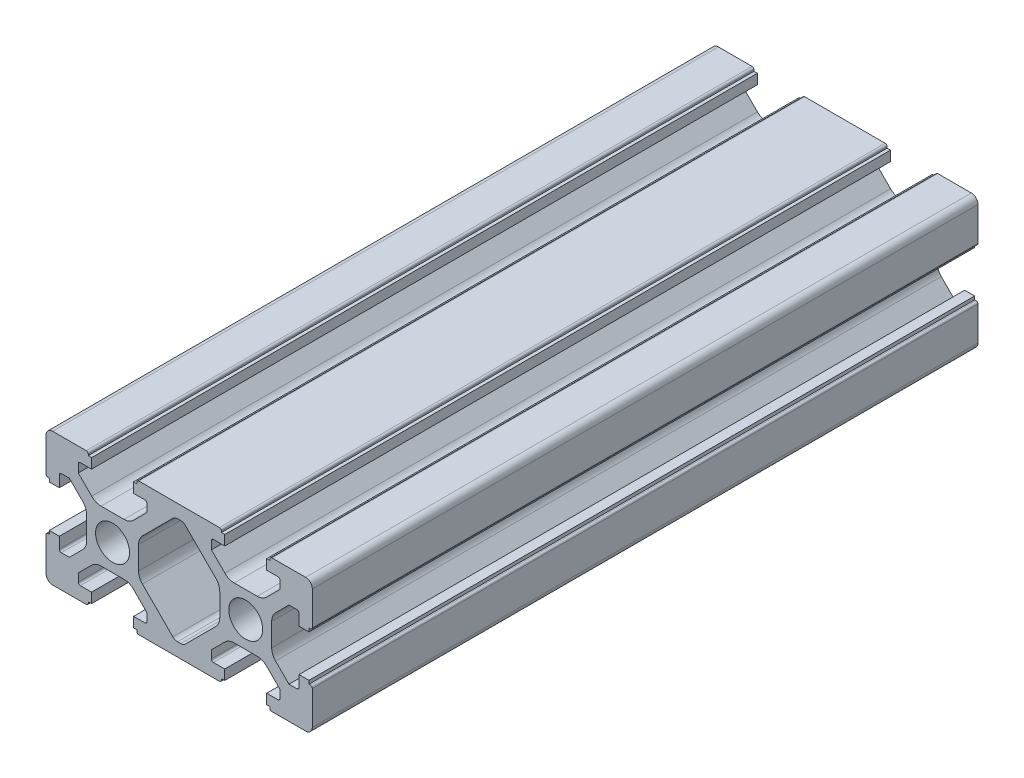
from build123d import *

# Parameters (mm, degrees)
SKETCH_1_R      = 2.55
EXTRUDE_1_DEPTH = 100


with BuildPart() as part:
    # 草图1 → 凸台-拉伸1 (new body)
    with BuildSketch(Plane.XY):
        with BuildLine():
            Line((-23.165408345, -6.388804564), (-23.165408345, -1.338804564))
            ThreePointArc((-23.165408345, -1.338804564), (-23.077540379, -1.12667253), (-22.865408345, -1.038804564))
            Line((-22.865408345, -1.038804564), (-22.665408345, -1.038804564))
            Line((-22.665408345, -1.038804564), (-22.665408345, -0.538804564))
            Line((-22.665408345, -0.538804564), (-21.165408345, -0.538804564))
            Line((-21.165408345, -0.538804564), (-21.165408345, -2.238804564))
            ThreePointArc((-21.165408345, -2.238804564), (-21.077540379, -2.450936598), (-20.865408345, -2.538804564))
            Line((-20.865408345, -2.538804564), (-19.665408345, -2.538804564))
            Line((-19.665408345, -2.538804564), (-17.651194783, -0.524591002))
            ThreePointArc((-17.651194783, -0.524591002), (-17.21764928, 0.124255696), (-17.065408345, 0.889622561))
            Line((-17.065408345, 0.889622561), (-17.065408345, 4.332768311))
            ThreePointArc((-17.065408345, 4.332768311), (-17.21764928, 5.098135176), (-17.651194783, 5.746981874))
            Line((-17.651194783, 5.746981874), (-19.665408345, 7.761195436))
            Line((-19.665408345, 7.761195436), (-20.865408345, 7.761195436))
            ThreePointArc((-20.865408345, 7.761195436), (-21.077540379, 7.67332747), (-21.165408345, 7.461195436))
            Line((-21.165408345, 7.461195436), (-21.165408345, 5.761195436))
            Line((-21.165408345, 5.761195436), (-22.665408345, 5.761195436))
            Line((-22.665408345, 5.761195436), (-22.665408345, 6.261195436))
            Line((-22.665408345, 6.261195436), (-22.865408345, 6.261195436))
            ThreePointArc((-22.865408345, 6.261195436), (-23.077540379, 6.349063402), (-23.165408345, 6.561195436))
            Line((-23.165408345, 6.561195436), (-23.165408345, 11.611195436))
            ThreePointArc((-23.165408345, 11.611195436), (-22.872515126, 12.318302217), (-22.165408345, 12.611195436))
            Line((-22.165408345, 12.611195436), (-17.115408345, 12.611195436))
            ThreePointArc((-17.115408345, 12.611195436), (-16.903276311, 12.52332747), (-16.815408345, 12.311195436))
            Line((-16.815408345, 12.311195436), (-16.815408345, 12.111195436))
            Line((-16.815408345, 12.111195436), (-16.315408345, 12.111195436))
            Line((-16.315408345, 12.111195436), (-16.315408345, 10.611195436))
            Line((-16.315408345, 10.611195436), (-18.015408345, 10.611195436))
            ThreePointArc((-18.015408345, 10.611195436), (-18.227540379, 10.52332747), (-18.315408345, 10.311195436))
            Line((-18.315408345, 10.311195436), (-18.315408345, 9.111195436))
            Line((-18.315408345, 9.111195436), (-16.301194783, 7.096981874))
            ThreePointArc((-16.301194783, 7.096981874), (-15.652348085, 6.663436371), (-14.88698122, 6.511195436))
            Line((-14.88698122, 6.511195436), (-11.44383547, 6.511195436))
            ThreePointArc((-11.44383547, 6.511195436), (-10.678468605, 6.663436371), (-10.029621907, 7.096981874))
            Line((-10.029621907, 7.096981874), (-8.015408345, 9.111195436))
            Line((-8.015408345, 9.111195436), (-8.015408345, 10.311195436))
            ThreePointArc((-8.015408345, 10.311195436), (-8.103276311, 10.52332747), (-8.315408345, 10.611195436))
            Line((-8.315408345, 10.611195436), (-10.015408345, 10.611195436))
            Line((-10.015408345, 10.611195436), (-10.015408345, 12.111195436))
            Line((-10.015408345, 12.111195436), (-9.515408345, 12.111195436))
            Line((-9.515408345, 12.111195436), (-9.515408345, 12.311195436))
            ThreePointArc((-9.515408345, 12.311195436), (-9.427540379, 12.52332747), (-9.215408345, 12.611195436))
            Line((-9.215408345, 12.611195436), (2.884591655, 12.611195436))
            ThreePointArc((2.884591655, 12.611195436), (3.096723689, 12.52332747), (3.184591655, 12.311195436))
            Line((3.184591655, 12.311195436), (3.184591655, 12.111195436))
            Line((3.184591655, 12.111195436), (3.684591655, 12.111195436))
            Line((3.684591655, 12.111195436), (3.684591655, 10.611195436))
            Line((3.684591655, 10.611195436), (1.984591655, 10.611195436))
            ThreePointArc((1.984591655, 10.611195436), (1.772459621, 10.52332747), (1.684591655, 10.311195436))
            Line((1.684591655, 10.311195436), (1.684591655, 9.111195436))
            Line((1.684591655, 9.111195436), (3.698805217, 7.096981874))
            ThreePointArc((3.698805217, 7.096981874), (4.347651915, 6.663436371), (5.11301878, 6.511195436))
            Line((5.11301878, 6.511195436), (8.55616453, 6.511195436))
            ThreePointArc((8.55616453, 6.511195436), (9.321531395, 6.663436371), (9.970378093, 7.096981874))
            Line((9.970378093, 7.096981874), (11.984591655, 9.111195436))
            Line((11.984591655, 9.111195436), (11.984591655, 10.311195436))
            ThreePointArc((11.984591655, 10.311195436), (11.896723689, 10.52332747), (11.684591655, 10.611195436))
            Line((11.684591655, 10.611195436), (9.984591655, 10.611195436))
            Line((9.984591655, 10.611195436), (9.984591655, 12.111195436))
            Line((9.984591655, 12.111195436), (10.484591655, 12.111195436))
            Line((10.484591655, 12.111195436), (10.484591655, 12.311195436))
            ThreePointArc((10.484591655, 12.311195436), (10.572459621, 12.52332747), (10.784591655, 12.611195436))
            Line((10.784591655, 12.611195436), (15.834591655, 12.611195436))
            ThreePointArc((15.834591655, 12.611195436), (16.541698436, 12.318302217), (16.834591655, 11.611195436))
            Line((16.834591655, 11.611195436), (16.834591655, 6.561195436))
            ThreePointArc((16.834591655, 6.561195436), (16.746723689, 6.349063402), (16.534591655, 6.261195436))
            Line((16.534591655, 6.261195436), (16.334591655, 6.261195436))
            Line((16.334591655, 6.261195436), (16.334591655, 5.761195436))
            Line((16.334591655, 5.761195436), (14.834591655, 5.761195436))
            Line((14.834591655, 5.761195436), (14.834591655, 7.461195436))
            ThreePointArc((14.834591655, 7.461195436), (14.746723689, 7.67332747), (14.534591655, 7.761195436))
            Line((14.534591655, 7.761195436), (13.334591655, 7.761195436))
            Line((13.334591655, 7.761195436), (11.320378093, 5.746981874))
            ThreePointArc((11.320378093, 5.746981874), (10.88683259, 5.098135176), (10.734591655, 4.332768311))
            Line((10.734591655, 4.332768311), (10.734591655, 0.889622561))
            ThreePointArc((10.734591655, 0.889622561), (10.88683259, 0.124255696), (11.320378093, -0.524591002))
            Line((11.320378093, -0.524591002), (13.334591655, -2.538804564))
            Line((13.334591655, -2.538804564), (14.534591655, -2.538804564))
            ThreePointArc((14.534591655, -2.538804564), (14.746723689, -2.450936598), (14.834591655, -2.238804564))
            Line((14.834591655, -2.238804564), (14.834591655, -0.538804564))
            Line((14.834591655, -0.538804564), (16.334591655, -0.538804564))
            Line((16.334591655, -0.538804564), (16.334591655, -1.038804564))
            Line((16.334591655, -1.038804564), (16.534591655, -1.038804564))
            ThreePointArc((16.534591655, -1.038804564), (16.746723689, -1.12667253), (16.834591655, -1.338804564))
            Line((16.834591655, -1.338804564), (16.834591655, -6.388804564))
            ThreePointArc((16.834591655, -6.388804564), (16.541698436, -7.095911345), (15.834591655, -7.388804564))
            Line((15.834591655, -7.388804564), (10.484591655, -7.388804564))
            Line((10.484591655, -7.388804564), (10.484591655, -6.888804564))
            Line((10.484591655, -6.888804564), (9.984591655, -6.888804564))
            Line((9.984591655, -6.888804564), (9.984591655, -5.388804564))
            Line((9.984591655, -5.388804564), (11.684591655, -5.388804564))
            ThreePointArc((11.684591655, -5.388804564), (11.896723689, -5.300936598), (11.984591655, -5.088804564))
            Line((11.984591655, -5.088804564), (11.984591655, -3.888804564))
            Line((11.984591655, -3.888804564), (9.970378093, -1.874591002))
            ThreePointArc((9.970378093, -1.874591002), (9.321531395, -1.441045499), (8.55616453, -1.288804564))
            Line((8.55616453, -1.288804564), (5.11301878, -1.288804564))
            ThreePointArc((5.11301878, -1.288804564), (4.347651915, -1.441045499), (3.698805217, -1.874591002))
            Line((3.698805217, -1.874591002), (1.684591655, -3.888804564))
            Line((1.684591655, -3.888804564), (1.684591655, -5.088804564))
            ThreePointArc((1.684591655, -5.088804564), (1.772459621, -5.300936598), (1.984591655, -5.388804564))
            Line((1.984591655, -5.388804564), (3.684591655, -5.388804564))
            Line((3.684591655, -5.388804564), (3.684591655, -6.888804564))
            Line((3.684591655, -6.888804564), (3.184591655, -6.888804564))
            Line((3.184591655, -6.888804564), (3.184591655, -7.088804564))
            ThreePointArc((3.184591655, -7.088804564), (3.096723689, -7.300936598), (2.884591655, -7.388804564))
            Line((2.884591655, -7.388804564), (-3.165408345, -7.388804564))
            Line((-3.165408345, -7.388804564), (-9.215408345, -7.388804564))
            ThreePointArc((-9.215408345, -7.388804564), (-9.427540379, -7.300936598), (-9.515408345, -7.088804564))
            Line((-9.515408345, -7.088804564), (-9.515408345, -6.888804564))
            Line((-9.515408345, -6.888804564), (-10.015408345, -6.888804564))
            Line((-10.015408345, -6.888804564), (-10.015408345, -5.388804564))
            Line((-10.015408345, -5.388804564), (-8.315408345, -5.388804564))
            ThreePointArc((-8.315408345, -5.388804564), (-8.103276311, -5.300936598), (-8.015408345, -5.088804564))
            Line((-8.015408345, -5.088804564), (-8.015408345, -3.888804564))
            Line((-8.015408345, -3.888804564), (-10.029621907, -1.874591002))
            ThreePointArc((-10.029621907, -1.874591002), (-10.678468605, -1.441045499), (-11.44383547, -1.288804564))
            Line((-11.44383547, -1.288804564), (-14.88698122, -1.288804564))
            ThreePointArc((-14.88698122, -1.288804564), (-15.652348085, -1.441045499), (-16.301194783, -1.874591002))
            Line((-16.301194783, -1.874591002), (-18.315408345, -3.888804564))
            Line((-18.315408345, -3.888804564), (-18.315408345, -5.088804564))
            ThreePointArc((-18.315408345, -5.088804564), (-18.227540379, -5.300936598), (-18.015408345, -5.388804564))
            Line((-18.015408345, -5.388804564), (-16.315408345, -5.388804564))
            Line((-16.315408345, -5.388804564), (-16.315408345, -6.888804564))
            Line((-16.315408345, -6.888804564), (-16.815408345, -6.888804564))
            Line((-16.815408345, -6.888804564), (-16.815408345, -7.088804564))
            ThreePointArc((-16.815408345, -7.088804564), (-16.903276311, -7.300936598), (-17.115408345, -7.388804564))
            Line((-17.115408345, -7.388804564), (-22.165408345, -7.388804564))
            ThreePointArc((-22.165408345, -7.388804564), (-22.872515126, -7.095911345), (-23.165408345, -6.388804564))
        make_face()
        with Locations((-13.165408345, 2.611195436)):
            Circle(SKETCH_1_R, mode=Mode.SUBTRACT)
        with Locations((6.834591655, 2.611195436)):
            Circle(SKETCH_1_R, mode=Mode.SUBTRACT)
        with BuildLine():
            Line((-9.265408345, 4.332768311), (-9.265408345, 0.889622561))
            ThreePointArc((-9.265408345, 0.889622561), (-9.11316741, 0.124255696), (-8.679621907, -0.524591002))
            Line((-8.679621907, -0.524591002), (-6.665408345, -2.538804564))
            Line((-6.665408345, -2.538804564), (-4.108301564, -5.095911345))
            ThreePointArc((-4.108301564, -5.095911345), (-3.783878215, -5.312684096), (-3.401194783, -5.388804564))
            Line((-3.401194783, -5.388804564), (-2.929621907, -5.388804564))
            ThreePointArc((-2.929621907, -5.388804564), (-2.546938475, -5.312684096), (-2.222515126, -5.095911345))
            Line((-2.222515126, -5.095911345), (0.334591655, -2.538804564))
            Line((0.334591655, -2.538804564), (2.348805217, -0.524591002))
            ThreePointArc((2.348805217, -0.524591002), (2.78235072, 0.124255696), (2.934591655, 0.889622561))
            Line((2.934591655, 0.889622561), (2.934591655, 4.332768311))
            ThreePointArc((2.934591655, 4.332768311), (2.78235072, 5.098135176), (2.348805217, 5.746981874))
            Line((2.348805217, 5.746981874), (0.334591655, 7.761195436))
            Line((0.334591655, 7.761195436), (-2.222515126, 10.318302217))
            ThreePointArc((-2.222515126, 10.318302217), (-2.546938475, 10.535074969), (-2.929621907, 10.611195436))
            Line((-2.929621907, 10.611195436), (-3.401194783, 10.611195436))
            ThreePointArc((-3.401194783, 10.611195436), (-3.783878215, 10.535074969), (-4.108301564, 10.318302217))
            Line((-4.108301564, 10.318302217), (-6.665408345, 7.761195436))
            Line((-6.665408345, 7.761195436), (-8.679621907, 5.746981874))
            ThreePointArc((-8.679621907, 5.746981874), (-9.11316741, 5.098135176), (-9.265408345, 4.332768311))
        make_face(mode=Mode.SUBTRACT)
    extrude(amount=EXTRUDE_1_DEPTH)


solid = part.part
